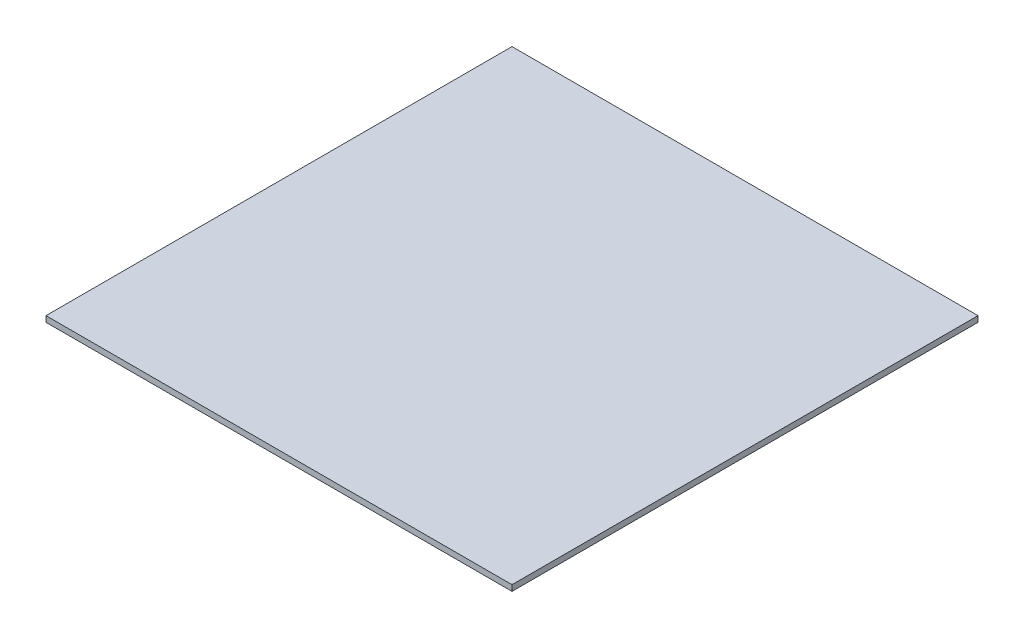
from build123d import *

# Parameters (mm, degrees)
SKETCH1_W           = 160
SKETCH1_H           = 160
BOSS_EXTRUDE1_DEPTH = 2


with BuildPart() as part:
    # Sketch1 → Boss-Extrude1 (new body)
    with BuildSketch(Plane(origin=(0, 0, 0), x_dir=(1, 0, 0), z_dir=(0, 1, 0))):
        with Locations((-80, 80)):
            Rectangle(SKETCH1_W, SKETCH1_H)
    extrude(amount=BOSS_EXTRUDE1_DEPTH)


solid = part.part
